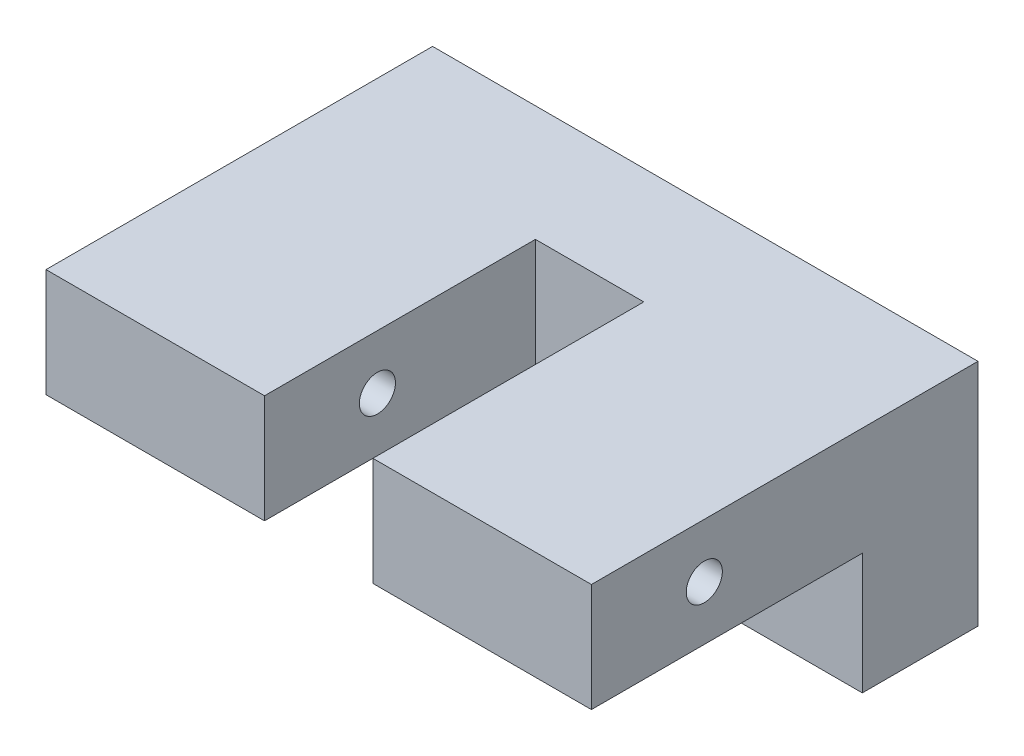
from build123d import *

# Parameters (mm, degrees)
SKETCH1_W           = 120.8
SKETCH1_H           = 50.8
BOSS_EXTRUDE1_DEPTH = 85.62
SKETCH2_W           = 24
SKETCH2_H           = 50.8
CUT_EXTRUDE1_DEPTH  = 60
SKETCH3_R           = 4
CUT_EXTRUDE2_DEPTH  = 121.8
SKETCH4_W           = 26.8
SKETCH4_H           = 60
CUT_EXTRUDE3_DEPTH  = 121.8


with BuildPart() as part:
    # Sketch1 → Boss-Extrude1 (new body)
    with BuildSketch(Plane.XY):
        with Locations((60.4, 25.4)):
            Rectangle(SKETCH1_W, SKETCH1_H)
    extrude(amount=BOSS_EXTRUDE1_DEPTH)

    # Sketch2 → Cut-Extrude1 (cut)
    with BuildSketch(Plane.XY.offset(85.62)):
        with Locations((60.4, 25.4)):
            Rectangle(SKETCH2_W, SKETCH2_H)
    extrude(amount=-CUT_EXTRUDE1_DEPTH, mode=Mode.SUBTRACT)

    # Sketch3 → Cut-Extrude2 (cut, through all)
    with BuildSketch(Plane.YZ.offset(120.8)):
        with Locations((38.8, 60.62)):
            Circle(SKETCH3_R)
    extrude(amount=-CUT_EXTRUDE2_DEPTH, mode=Mode.SUBTRACT)

    # Sketch4 → Cut-Extrude3 (cut, through all)
    with BuildSketch(Plane.YZ.offset(120.8)):
        with Locations((13.4, 55.62)):
            Rectangle(SKETCH4_W, SKETCH4_H)
    extrude(amount=-CUT_EXTRUDE3_DEPTH, mode=Mode.SUBTRACT)


solid = part.part
